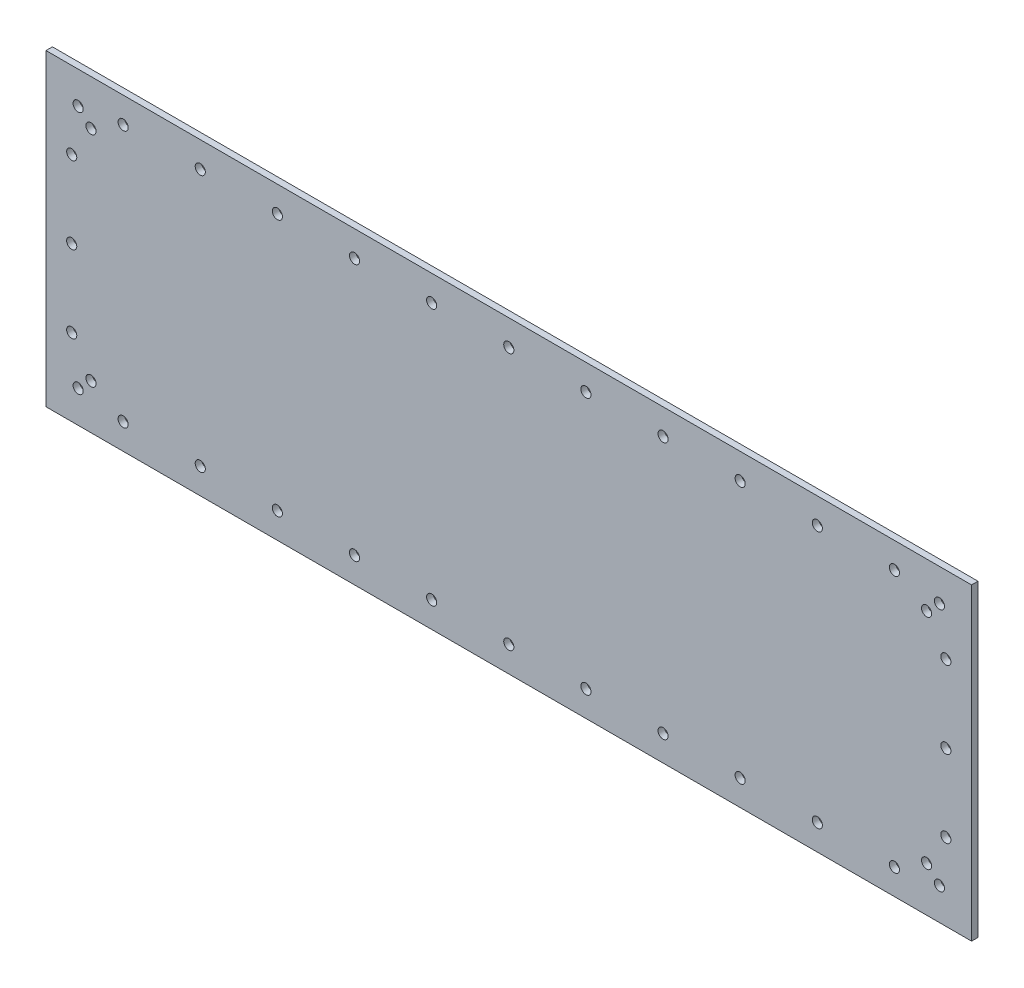
from build123d import *

# Parameters (mm, degrees)
SKETCH1_W           = 457.2
SKETCH1_H           = 152.4
SKETCH1_R           = 2.5
BOSS_EXTRUDE1_DEPTH = 3.175


with BuildPart() as part:
    # Sketch1 → Boss-Extrude1 (new body)
    with BuildSketch(Plane.XY):
        Rectangle(SKETCH1_W, SKETCH1_H)
        with Locations((212.725, 60.325)):
            Circle(SKETCH1_R, mode=Mode.SUBTRACT)
        with Locations((206.375, 53.975)):
            Circle(SKETCH1_R, mode=Mode.SUBTRACT)
        with Locations((-206.375, 53.975)):
            Circle(SKETCH1_R, mode=Mode.SUBTRACT)
        with Locations((-212.725, 60.325)):
            Circle(SKETCH1_R, mode=Mode.SUBTRACT)
        with Locations((-212.725, -60.325)):
            Circle(SKETCH1_R, mode=Mode.SUBTRACT)
        with Locations((-206.375, -53.975)):
            Circle(SKETCH1_R, mode=Mode.SUBTRACT)
        with Locations((206.375, -53.975)):
            Circle(SKETCH1_R, mode=Mode.SUBTRACT)
        with Locations((212.725, -60.325)):
            Circle(SKETCH1_R, mode=Mode.SUBTRACT)
        with Locations((-190.5, 63.5)):
            Circle(SKETCH1_R, mode=Mode.SUBTRACT)
        with Locations((-152.4, 63.5)):
            Circle(SKETCH1_R, mode=Mode.SUBTRACT)
        with Locations((-114.3, 63.5)):
            Circle(SKETCH1_R, mode=Mode.SUBTRACT)
        with Locations((-76.2, 63.5)):
            Circle(SKETCH1_R, mode=Mode.SUBTRACT)
        with Locations((-38.1, 63.5)):
            Circle(SKETCH1_R, mode=Mode.SUBTRACT)
        with Locations((0, 63.5)):
            Circle(SKETCH1_R, mode=Mode.SUBTRACT)
        with Locations((38.1, 63.5)):
            Circle(SKETCH1_R, mode=Mode.SUBTRACT)
        with Locations((76.2, 63.5)):
            Circle(SKETCH1_R, mode=Mode.SUBTRACT)
        with Locations((114.3, 63.5)):
            Circle(SKETCH1_R, mode=Mode.SUBTRACT)
        with Locations((152.4, 63.5)):
            Circle(SKETCH1_R, mode=Mode.SUBTRACT)
        with Locations((190.5, 63.5)):
            Circle(SKETCH1_R, mode=Mode.SUBTRACT)
        with Locations((-215.9, 38.1)):
            Circle(SKETCH1_R, mode=Mode.SUBTRACT)
        with Locations((-215.9, 0)):
            Circle(SKETCH1_R, mode=Mode.SUBTRACT)
        with Locations((-215.9, -38.1)):
            Circle(SKETCH1_R, mode=Mode.SUBTRACT)
        with Locations((190.5, -63.5)):
            Circle(SKETCH1_R, mode=Mode.SUBTRACT)
        with Locations((152.4, -63.5)):
            Circle(SKETCH1_R, mode=Mode.SUBTRACT)
        with Locations((114.3, -63.5)):
            Circle(SKETCH1_R, mode=Mode.SUBTRACT)
        with Locations((76.2, -63.5)):
            Circle(SKETCH1_R, mode=Mode.SUBTRACT)
        with Locations((38.1, -63.5)):
            Circle(SKETCH1_R, mode=Mode.SUBTRACT)
        with Locations((0, -63.5)):
            Circle(SKETCH1_R, mode=Mode.SUBTRACT)
        with Locations((-38.1, -63.5)):
            Circle(SKETCH1_R, mode=Mode.SUBTRACT)
        with Locations((-76.2, -63.5)):
            Circle(SKETCH1_R, mode=Mode.SUBTRACT)
        with Locations((-114.3, -63.5)):
            Circle(SKETCH1_R, mode=Mode.SUBTRACT)
        with Locations((-152.4, -63.5)):
            Circle(SKETCH1_R, mode=Mode.SUBTRACT)
        with Locations((-190.5, -63.5)):
            Circle(SKETCH1_R, mode=Mode.SUBTRACT)
        with Locations((215.9, -38.1)):
            Circle(SKETCH1_R, mode=Mode.SUBTRACT)
        with Locations((215.9, 0)):
            Circle(SKETCH1_R, mode=Mode.SUBTRACT)
        with Locations((215.9, 38.1)):
            Circle(SKETCH1_R, mode=Mode.SUBTRACT)
    extrude(amount=BOSS_EXTRUDE1_DEPTH)


solid = part.part
